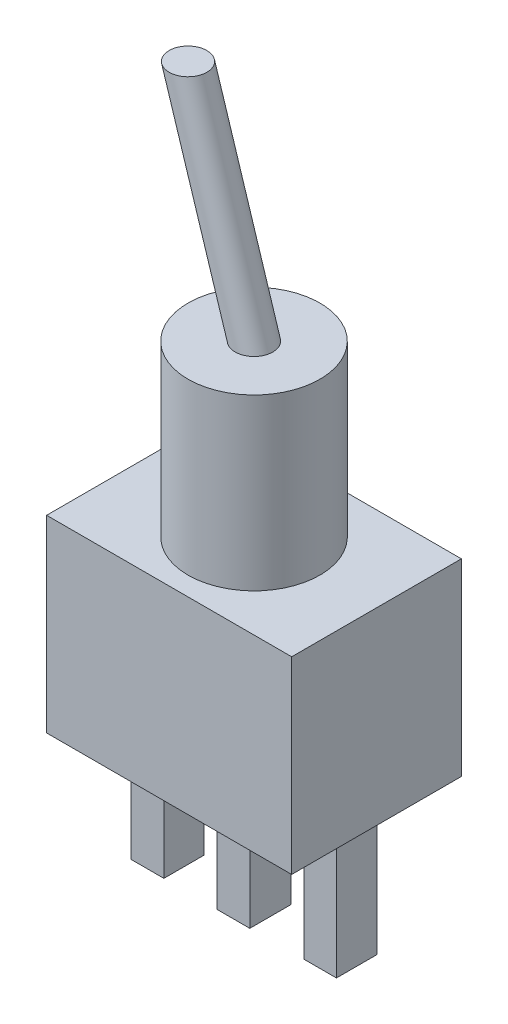
from build123d import *

# Parameters (mm, degrees)
SKETCH_1_W      = 13
SKETCH_1_H      = 9
EXTRUDE_1_DEPTH = 10
SKETCH_2_R      = 3.5
EXTRUDE_2_DEPTH = 9
SKETCH_4_R      = 1
SKETCH_5_W      = 1.73309276
SKETCH_5_H      = 2.139523058
SKETCH_5_W_2    = 1.729366682
SKETCH_5_H_2    = 2.174749504
EXTRUDE_3_DEPTH = 7


with BuildPart() as part:
    # 草图1 → 凸台-拉伸1 (new body)
    with BuildSketch(Plane(origin=(0, 0, 0), x_dir=(1, 0, 0), z_dir=(0, 1, 0))):
        Rectangle(SKETCH_1_W, SKETCH_1_H)
    extrude(amount=EXTRUDE_1_DEPTH)

    # 草图2 → 凸台-拉伸2 (add)
    with BuildSketch(Plane(origin=(0, 10, 0), x_dir=(1, 0, 0), z_dir=(0, 1, 0))):
        Circle(SKETCH_2_R)
    extrude(amount=EXTRUDE_2_DEPTH)

    # 扫描1: sweep along a path in 草图3
    with BuildLine(Plane.XY) as sweep_1_path:
        Line((0, 19), (-3.5, 30.100205658))
    # 草图4 → 扫描1 (sweep)
    with BuildSketch(Plane(origin=(0, 19, 0), x_dir=(1, 0, 0), z_dir=(0, 1, 0))):
        Circle(SKETCH_4_R)
    sweep(path=sweep_1_path.line)

    # 草图5 → 凸台-拉伸3 (add)
    with BuildSketch(Plane(origin=(0, 0, 0), x_dir=(-1, 0, 0), z_dir=(0, -1, 0))):
        with Locations((-4.576618424, 0)):
            Rectangle(SKETCH_5_W, SKETCH_5_H)
        with Locations((4.576618424, 0)):
            Rectangle(SKETCH_5_W, SKETCH_5_H)
        Rectangle(SKETCH_5_W_2, SKETCH_5_H_2)
    extrude(amount=EXTRUDE_3_DEPTH)


solid = part.part
